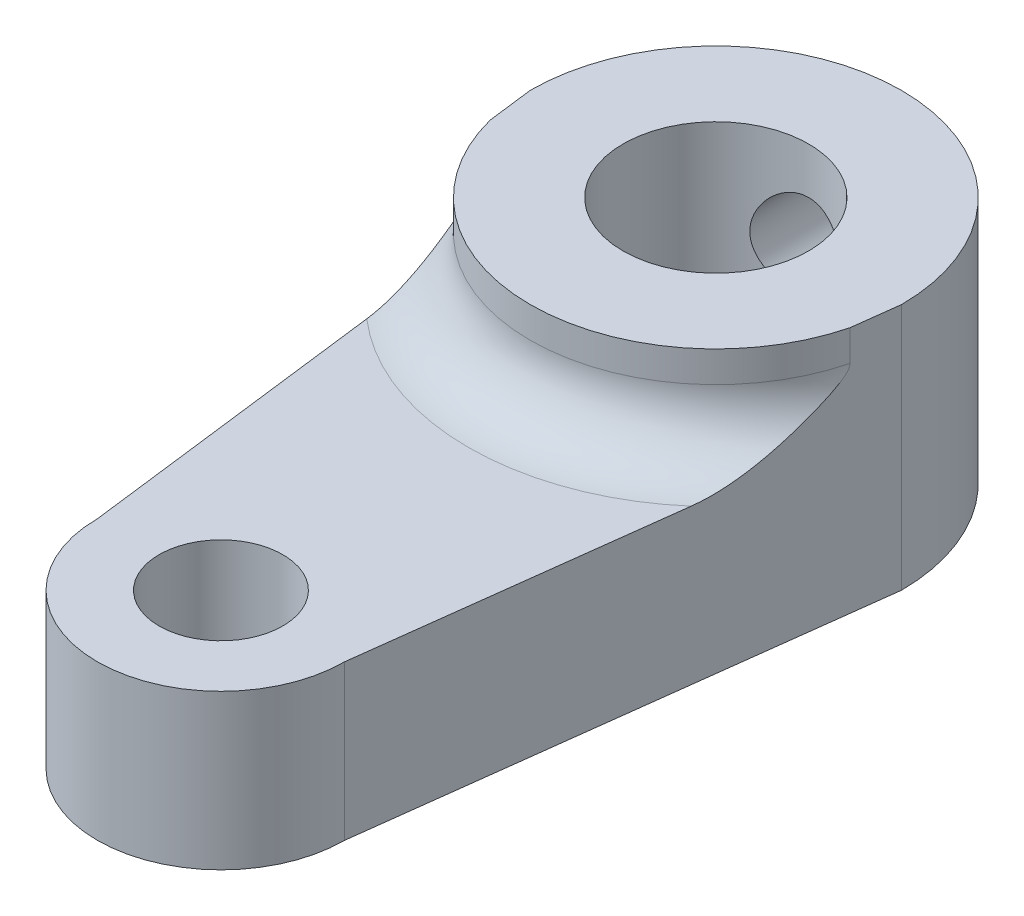
from build123d import *

# Parameters (mm, degrees)
SKETCH1_R             = 3
BOSS_EXTRUDE1_DEPTH   = 8
SKETCH1_3_R           = 2
BOSS_EXTRUDE2_DEPTH   = 5
FILLET1_R             = 2
M3_TAPPED_HOLE1_D     = 3
M3_TAPPED_HOLE1_DEPTH = 8.5
M3_TAPPED_HOLE1_TIP   = 0.901290929


with BuildPart() as part:
    # Sketch1 → Boss-Extrude1 (new body)
    with BuildSketch(Plane(origin=(0, 0, 0), x_dir=(1, 0, 0), z_dir=(0, 1, 0))):
        with BuildLine():
            ThreePointArc((6, 0), (0, 6), (-6, 0))
            Line((-6, 0), (-5.815384615, -1.476923077))
            ThreePointArc((-5.815384615, -1.476923077), (0, -6), (5.815384615, -1.476923077))
            Line((5.815384615, -1.476923077), (6, 0))
        make_face()
        Circle(SKETCH1_R, mode=Mode.SUBTRACT)
    extrude(amount=BOSS_EXTRUDE1_DEPTH)

    # Sketch1_3 → Boss-Extrude2 (add)
    with BuildSketch(Plane(origin=(0, 0, 0), x_dir=(1, 0, 0), z_dir=(0, 1, 0))):
        with BuildLine():
            ThreePointArc((5.815384615, -1.476923077), (0, -6), (-5.815384615, -1.476923077))
            Line((-5.815384615, -1.476923077), (-4, -16))
            ThreePointArc((-4, -16), (0, -20), (4, -16))
            Line((4, -16), (5.815384615, -1.476923077))
        make_face()
        with Locations((0, -16)):
            Circle(SKETCH1_3_R, mode=Mode.SUBTRACT)
    extrude(amount=BOSS_EXTRUDE2_DEPTH)

    # Fillet1
    fillet1_edges = [part.edges().sort_by_distance(p)[0] for p in [
        (0, 5, 6),
    ]]
    fillet(fillet1_edges, radius=FILLET1_R)

    # M3 Tapped Hole1
    with Locations(Plane(origin=(0, 0, -8), x_dir=(1, 0, 0), z_dir=(0, 0, -1))):
        with Locations((0, -5)):
            Hole(M3_TAPPED_HOLE1_D / 2, depth=M3_TAPPED_HOLE1_DEPTH)
            with Locations((0, 0, -(M3_TAPPED_HOLE1_DEPTH + M3_TAPPED_HOLE1_TIP / 2))):  # 118° drill point
                Cone(0, M3_TAPPED_HOLE1_D / 2, M3_TAPPED_HOLE1_TIP, mode=Mode.SUBTRACT)


solid = part.part
